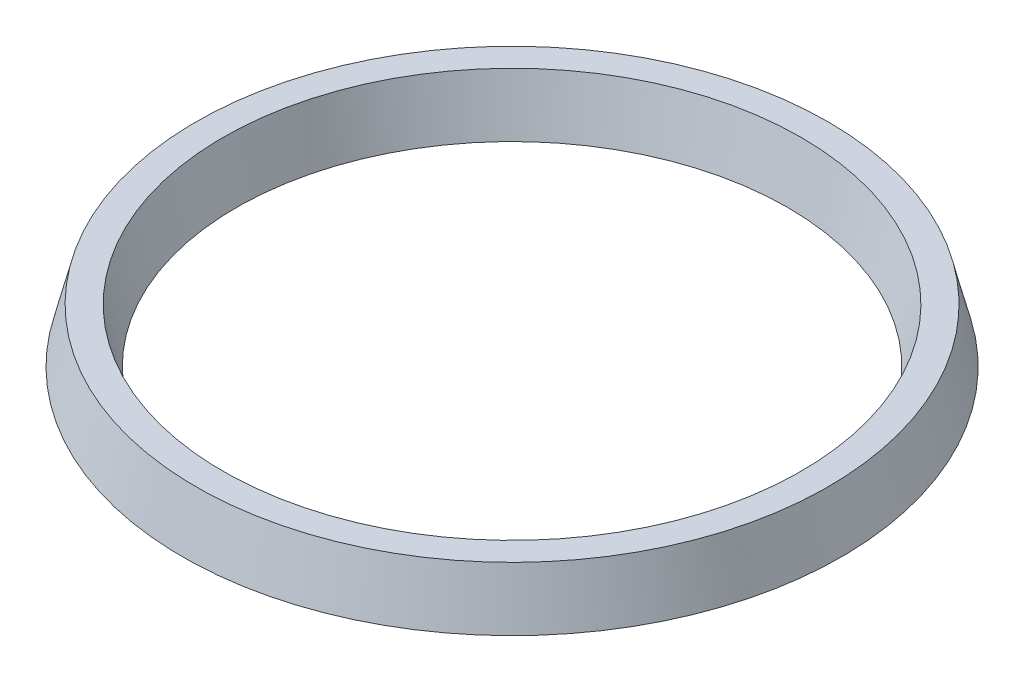
from build123d import *


with BuildPart() as part:
    # Sketch1 → Revolve1 (revolve)
    with BuildSketch(Plane(origin=(0, 0, 0), x_dir=(0, 0, -1), z_dir=(1, 0, 0))):
        with BuildLine():
            Line((64.31, 6), (70.31, 6))
            Line((70.31, 6), (73.31, -6))
            Line((73.31, -6), (70.31, -6))
            Line((70.31, -6), (69.173803438, -1.45521375))
            ThreePointArc((69.173803438, -1.45521375), (67.31, 0), (65.446196562, -1.45521375))
            Line((65.446196562, -1.45521375), (64.31, -6))
            Line((64.31, -6), (61.31, -6))
            Line((61.31, -6), (64.31, 6))
        make_face()
    revolve(axis=Axis((0, 0, 0), (0, 1, 0)))


solid = part.part
